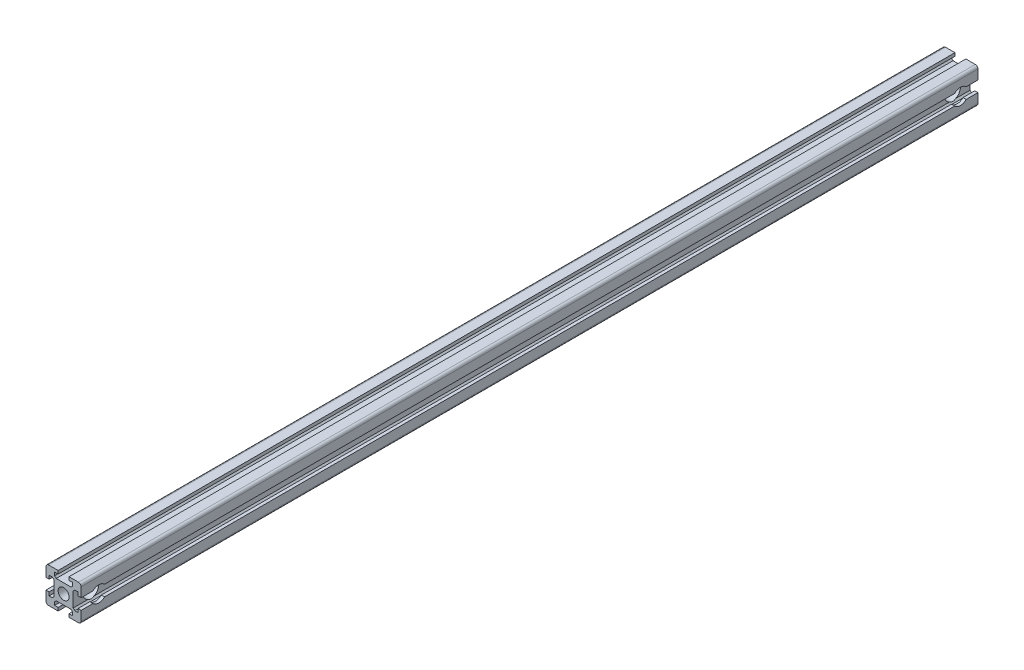
from build123d import *

# Parameters (mm, degrees)
SKETCH1_R               = 3.1
BOSS_EXTRUDE1_DEPTH     = 510
SKETCH3_R               = 4.5
CUT_EXTRUDE2_DEPTH      = 5.507107651
CUT_EXTRUDE2_DEPTH_BACK = 11


with BuildPart() as part:
    # Sketch1 → Boss-Extrude1 (new body)
    with BuildSketch(Plane.XY):
        with BuildLine():
            Line((-10, 3.1), (-8.2, 3.1))
            Line((-8.2, 3.1), (-8.2, 5.1))
            Line((-8.2, 5.1), (-6.4, 5.1))
            Line((-6.4, 5.1), (-5.492892349, 4.192892349))
            Line((-5.492892349, 4.192892349), (-5.492892349, -4.192892349))
            Line((-5.492892349, -4.192892349), (-6.4, -5.1))
            Line((-6.4, -5.1), (-8.2, -5.1))
            Line((-8.2, -5.1), (-8.2, -3.1))
            Line((-8.2, -3.1), (-10, -3.1))
            Line((-10, -3.1), (-10, -8.5))
            ThreePointArc((-10, -8.5), (-9.560660172, -9.560660172), (-8.5, -10))
            Line((-8.5, -10), (-3.1, -10))
            Line((-3.1, -10), (-3.1, -8.2))
            Line((-3.1, -8.2), (-5.1, -8.2))
            Line((-5.1, -8.2), (-5.1, -6.4))
            Line((-5.1, -6.4), (-4.192892349, -5.492892349))
            Line((-4.192892349, -5.492892349), (4.192892349, -5.492892349))
            Line((4.192892349, -5.492892349), (5.1, -6.4))
            Line((5.1, -6.4), (5.1, -8.2))
            Line((5.1, -8.2), (3.1, -8.2))
            Line((3.1, -8.2), (3.1, -10))
            Line((3.1, -10), (8.5, -10))
            ThreePointArc((8.5, -10), (9.560660172, -9.560660172), (10, -8.5))
            Line((10, -8.5), (10, -3.1))
            Line((10, -3.1), (8.2, -3.1))
            Line((8.2, -3.1), (8.2, -5.1))
            Line((8.2, -5.1), (6.4, -5.1))
            Line((6.4, -5.1), (5.492892349, -4.192892349))
            Line((5.492892349, -4.192892349), (5.492892349, 4.192892349))
            Line((5.492892349, 4.192892349), (6.4, 5.1))
            Line((6.4, 5.1), (8.2, 5.1))
            Line((8.2, 5.1), (8.2, 3.1))
            Line((8.2, 3.1), (10, 3.1))
            Line((10, 3.1), (10, 8.5))
            ThreePointArc((10, 8.5), (9.560660172, 9.560660172), (8.5, 10))
            Line((8.5, 10), (3.1, 10))
            Line((3.1, 10), (3.1, 8.2))
            Line((3.1, 8.2), (5.1, 8.2))
            Line((5.1, 8.2), (5.1, 6.4))
            Line((5.1, 6.4), (4.192892349, 5.492892349))
            Line((4.192892349, 5.492892349), (-4.192892349, 5.492892349))
            Line((-4.192892349, 5.492892349), (-5.1, 6.4))
            Line((-5.1, 6.4), (-5.1, 8.2))
            Line((-5.1, 8.2), (-3.1, 8.2))
            Line((-3.1, 8.2), (-3.1, 10))
            Line((-3.1, 10), (-8.5, 10))
            ThreePointArc((-8.5, 10), (-9.560660172, 9.560660172), (-10, 8.5))
            Line((-10, 8.5), (-10, 3.1))
        make_face()
        Circle(SKETCH1_R, mode=Mode.SUBTRACT)
    extrude(amount=BOSS_EXTRUDE1_DEPTH)

    # Sketch3 → Cut-Extrude2 (cut, two sides)
    with BuildSketch(Plane(origin=(5.492892349, 0, 0), x_dir=(0, 0, -1), z_dir=(1, 0, 0))) as cut_extrude2_sk:
        with Locations((-10, 0)):
            Circle(SKETCH3_R)
        with Locations((-500, 0)):
            Circle(SKETCH3_R)
    extrude(amount=CUT_EXTRUDE2_DEPTH, mode=Mode.SUBTRACT)
    extrude(cut_extrude2_sk.sketch, amount=-CUT_EXTRUDE2_DEPTH_BACK, mode=Mode.SUBTRACT)


solid = part.part
